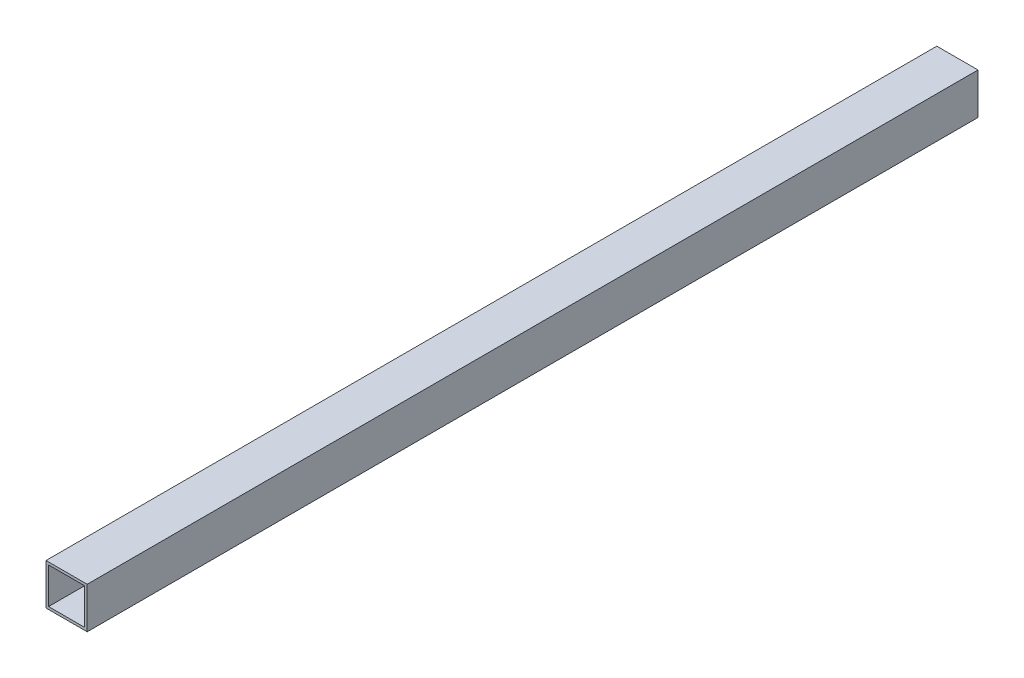
from build123d import *

# Parameters (mm, degrees)
SKETCH1_W           = 50.8
SKETCH1_H           = 50.8
SKETCH1_W_2         = 44.45
SKETCH1_H_2         = 44.45
BOSS_EXTRUDE1_DEPTH = 1098.55


with BuildPart() as part:
    # Sketch1 → Boss-Extrude1 (new body)
    with BuildSketch(Plane.XY):
        Rectangle(SKETCH1_W, SKETCH1_H)
        Rectangle(SKETCH1_W_2, SKETCH1_H_2, mode=Mode.SUBTRACT)
    extrude(amount=BOSS_EXTRUDE1_DEPTH)


solid = part.part
